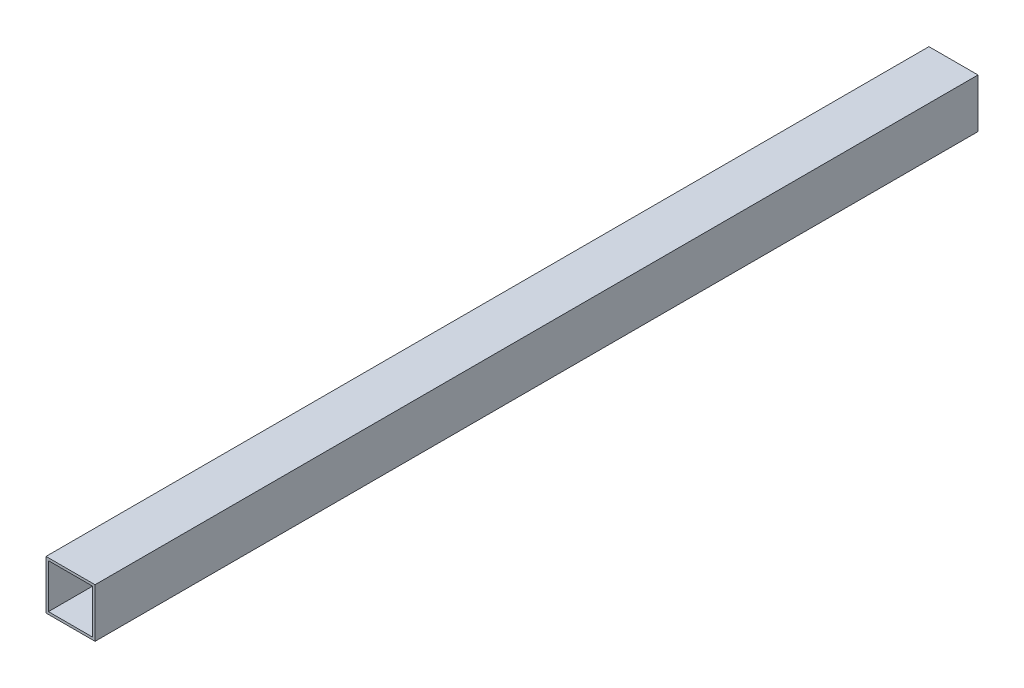
from build123d import *

# Parameters (mm, degrees)
SKETCH1_W           = 20
SKETCH1_H           = 20
SKETCH1_W_2         = 18
SKETCH1_H_2         = 18
BOSS_EXTRUDE1_DEPTH = 360


with BuildPart() as part:
    # Sketch1 → Boss-Extrude1 (new body)
    with BuildSketch(Plane.XY):
        with Locations((10, -10)):
            Rectangle(SKETCH1_W, SKETCH1_H)
        with Locations((10, -10)):
            Rectangle(SKETCH1_W_2, SKETCH1_H_2, mode=Mode.SUBTRACT)
    extrude(amount=BOSS_EXTRUDE1_DEPTH)


solid = part.part
